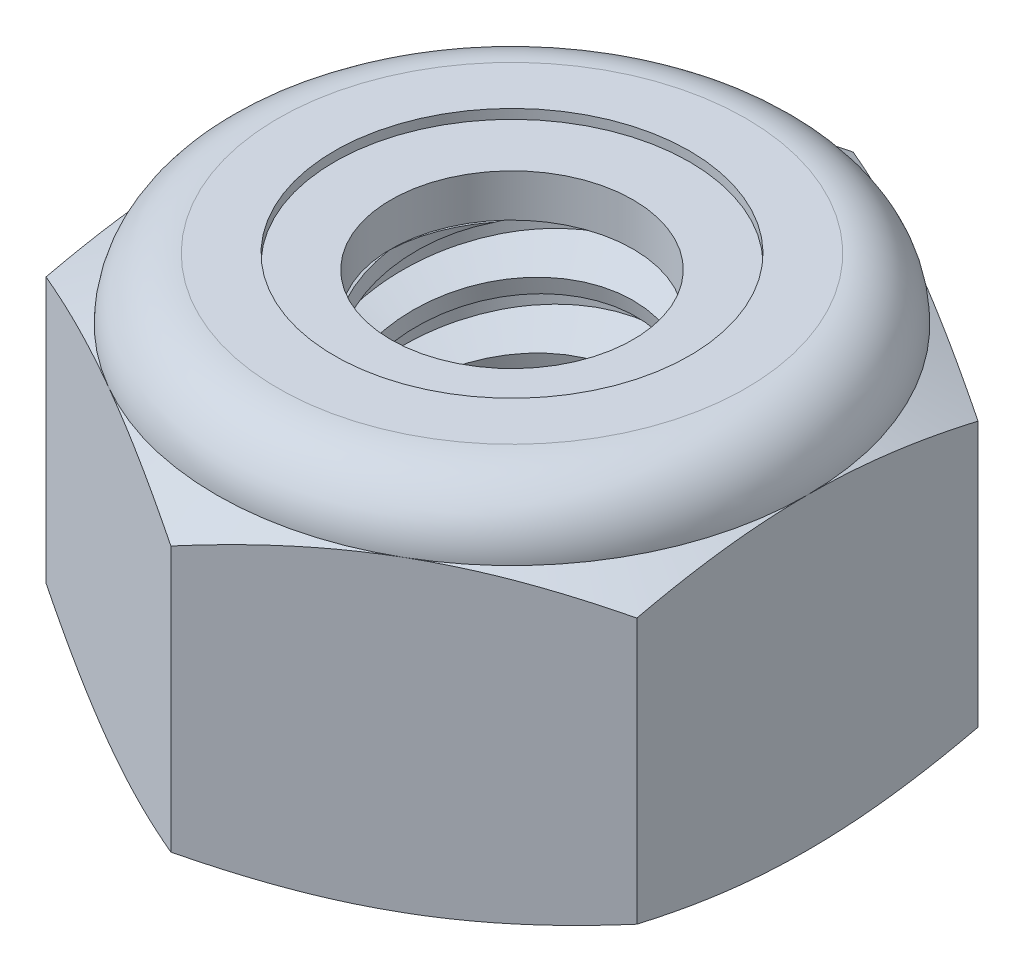
from build123d import *

# Parameters (mm, degrees)
EXTRUDE1_DEPTH      = 5.953125
SKETCH2_W           = 2.413
SKETCH2_H           = 5.953125
LPATTERN1_COUNT     = 6
LPATTERN1_PITCH     = 1.058333333
LPATTERN1_COL_COUNT = 2
LPATTERN1_COL_PITCH = 1.058333333


with BuildPart() as part:
    # Sketch1 → Extrude1 (new body)
    with BuildSketch(Plane(origin=(0, 0, 0), x_dir=(1, 0, 0), z_dir=(0, 1, 0))):
        Polygon((0, 5.499261314), (-4.7625, 2.749630657), (-4.7625, -2.749630657), (0, -5.499261314), (4.7625, -2.749630657), (4.7625, 2.749630657), align=None)
    extrude(amount=EXTRUDE1_DEPTH)

    # Sketch4 → Cut-Revolve2 (revolve, cut)
    with BuildSketch(Plane(origin=(0, 0, 0), x_dir=(0, 0, -1), z_dir=(1, 0, 0))):
        Polygon((0, 5.953125), (2.413, 5.953125), (1.952639712, 5.738455472), (1.952639712, 0.214669528), (2.413, 0), (0, 0), align=None)
    revolve(axis=Axis((0, 5.953125, 0), (0, 1, 0)), mode=Mode.SUBTRACT)


with BuildPart() as body_2:
    # Sketch2 → Revolve1 (revolve)
    with BuildSketch(Plane(origin=(0, 0, 0), x_dir=(0, 0, -1), z_dir=(1, 0, 0))):
        with Locations((1.2065, 2.9765625)):
            Rectangle(SKETCH2_W, SKETCH2_H)
    revolve(axis=Axis((0, -2.413, 0), (0, 1, 0)))

    # Sketch3 → Cut-Revolve1 (revolve, cut)
    with BuildSketch(Plane(origin=(0, 0, 0), x_dir=(0, 0, -1), z_dir=(1, 0, 0))):
        Polygon((2.441337922, 5.823904076), (2.639703376, 4.919357607), (2.009315556, 5.119703115), (1.952639712, 5.378144964), align=None)
    cut_revolve1 = revolve(axis=Axis((0, 5.953125, 0.249698658), (0, -0.976788088, -0.214207914)), mode=Mode.SUBTRACT)

    # LPattern1: Cut-Revolve1 ×6
    with Locations(*[(0, -i * LPATTERN1_PITCH, 0) for i in range(1, LPATTERN1_COUNT)]):
        add(cut_revolve1, mode=Mode.SUBTRACT)

    # LPattern1 col: Cut-Revolve1 ×2
    with Locations(*[(0, i * LPATTERN1_COL_PITCH, 0) for i in range(1, LPATTERN1_COL_COUNT)]):
        add(cut_revolve1, mode=Mode.SUBTRACT)


with BuildPart() as part_1:
    add(part.part)

    # Combine1: cut body 2
    add(body_2.part, mode=Mode.SUBTRACT)

    # Sketch5 → Cut-Revolve3 (revolve, cut)
    with BuildSketch(Plane(origin=(0, 0, 0), x_dir=(0, 0, -1), z_dir=(1, 0, 0))):
        with BuildLine():
            Line((0, 0), (4.7625, 0))
            Line((4.7625, 0), (5.499261314, 0.343557443))
            Line((5.499261314, 0.343557443), (5.499261314, 4.617380057))
            Line((5.499261314, 4.617380057), (4.7625, 4.9609375))
            ThreePointArc((4.7625, 4.9609375), (4.471895009, 5.662520009), (3.7703125, 5.953125))
            Line((3.7703125, 5.953125), (3.7703125, 7.223125))
            Line((3.7703125, 7.223125), (6.769261314, 7.223125))
            Line((6.769261314, 7.223125), (6.769261314, -1.27))
            Line((6.769261314, -1.27), (0, -1.27))
            Line((0, -1.27), (0, 0))
        make_face()
    revolve(axis=Axis((0, 0, 0), (0, 1, 0)), mode=Mode.SUBTRACT)

    # Sketch6 → Cut-Revolve4 (revolve, cut)
    with BuildSketch(Plane(origin=(0, 0, 0), x_dir=(0, 0, -1), z_dir=(1, 0, 0))):
        with BuildLine():
            Line((0, 4.9609375), (4.6101, 4.9609375))
            ThreePointArc((4.6101, 4.9609375), (4.364131936, 5.554756936), (3.7703125, 5.800725))
            Line((3.7703125, 5.800725), (2.861476106, 5.800725))
            Line((2.861476106, 5.800725), (2.861476106, 7.223125))
            Line((2.861476106, 7.223125), (0, 7.223125))
            Line((0, 7.223125), (0, 4.9609375))
        make_face()
    revolve(axis=Axis((0, 7.223125, 0), (0, 1, 0)), mode=Mode.SUBTRACT)


with BuildPart() as body_2_2:
    # Sketch7 → Revolve2 (revolve)
    with BuildSketch(Plane(origin=(0, 0, 0), x_dir=(0, 0, -1), z_dir=(1, 0, 0))):
        with BuildLine():
            Line((1.952639712, 5.0371375), (4.530088408, 5.0371375))
            ThreePointArc((4.530088408, 5.0371375), (4.282601726, 5.527175629), (3.7703125, 5.724525))
            Line((3.7703125, 5.724525), (1.952639712, 5.724525))
            Line((1.952639712, 5.724525), (1.952639712, 5.0371375))
        make_face()
    revolve(axis=Axis((0, 5.0371375, 0), (0, 1, 0)))


solid = Compound([part_1.part, body_2_2.part])
